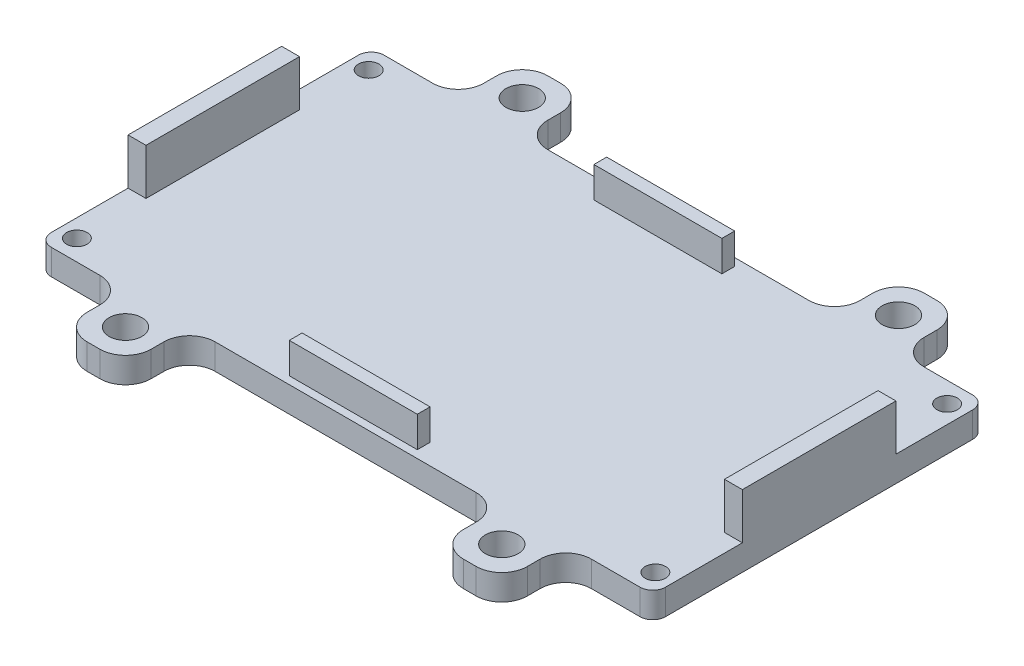
from build123d import *

# Parameters (mm, degrees)
SKETCH_1_W          = 120
SKETCH_1_H          = 65
EXTRUDE_1_DEPTH     = 5
SKETCH_2_W          = 12.5
SKETCH_2_H          = 12.5
EXTRUDE_2_DEPTH     = 5
SKETCH_3_R          = 3.2
CUT_EXTRUDE_1_DEPTH = 5
SKETCH_4_W          = 3.5
SKETCH_4_H          = 30
EXTRUDE_3_DEPTH     = 9
FILLET_1_R          = 5
FILLET_2_R          = 2.5
SKETCH_5_W          = 25
SKETCH_5_H          = 2.5
EXTRUDE_4_DEPTH     = 6
SKETCH_6_R          = 2
CUT_EXTRUDE_2_DEPTH = 10


with BuildPart() as part:
    # 草图1 → 凸台-拉伸1 (new body)
    with BuildSketch(Plane(origin=(0, 0, 0), x_dir=(1, 0, 0), z_dir=(0, 1, 0))):
        Rectangle(SKETCH_1_W, SKETCH_1_H)
    extrude(amount=EXTRUDE_1_DEPTH)

    # 草图2 → 凸台-拉伸2 (add)
    with BuildSketch(Plane(origin=(0, 5, 0), x_dir=(1, 0, 0), z_dir=(0, 1, 0))):
        with Locations((-36.75, 38.75)):
            Rectangle(SKETCH_2_W, SKETCH_2_H)
        with Locations((36.75, 38.75)):
            Rectangle(SKETCH_2_W, SKETCH_2_H)
        with Locations((36.75, -38.75)):
            Rectangle(SKETCH_2_W, SKETCH_2_H)
        with Locations((-36.75, -38.75)):
            Rectangle(SKETCH_2_W, SKETCH_2_H)
    extrude(amount=-EXTRUDE_2_DEPTH)

    # 草图3 → 切除-拉伸1 (cut)
    with BuildSketch(Plane(origin=(0, 5, 0), x_dir=(1, 0, 0), z_dir=(0, 1, 0))):
        with Locations((-36.75, 38.75)):
            Circle(SKETCH_3_R)
        with Locations((36.75, 38.75)):
            Circle(SKETCH_3_R)
        with Locations((36.75, -38.75)):
            Circle(SKETCH_3_R)
        with Locations((-36.75, -38.75)):
            Circle(SKETCH_3_R)
    extrude(amount=-CUT_EXTRUDE_1_DEPTH, mode=Mode.SUBTRACT)

    # 草图4 → 凸台-拉伸3 (add)
    with BuildSketch(Plane(origin=(0, 5, 0), x_dir=(1, 0, 0), z_dir=(0, 1, 0))):
        with Locations((-58.25, 0)):
            Rectangle(SKETCH_4_W, SKETCH_4_H)
        with Locations((58.25, 0)):
            Rectangle(SKETCH_4_W, SKETCH_4_H)
    extrude(amount=EXTRUDE_3_DEPTH)

    # 圆角1
    fillet_1_edges = [part.edges().sort_by_distance(p)[0] for p in [
        (-43, 2.5, -32.5),
        (-43, 2.5, -45),
        (-30.5, 2.5, -45),
        (-30.5, 2.5, -32.5),
        (43, 2.5, -32.5),
        (30.5, 2.5, -32.5),
        (30.5, 2.5, -45),
        (43, 2.5, -45),
        (30.5, 2.5, 32.5),
        (43, 2.5, 32.5),
        (43, 2.5, 45),
        (30.5, 2.5, 45),
        (-43, 2.5, 32.5),
        (-30.5, 2.5, 32.5),
        (-30.5, 2.5, 45),
        (-43, 2.5, 45),
    ]]
    fillet(fillet_1_edges, radius=FILLET_1_R)

    # 圆角2
    fillet_2_edges = [part.edges().sort_by_distance(p)[0] for p in [
        (60, 2.5, 32.5),
        (-60, 2.5, 32.5),
        (-60, 2.5, -32.5),
        (60, 2.5, -32.5),
    ]]
    fillet(fillet_2_edges, radius=FILLET_2_R)

    # 草图5 → 凸台-拉伸4 (add)
    with BuildSketch(Plane(origin=(0, 5, 0), x_dir=(1, 0, 0), z_dir=(0, 1, 0))):
        with Locations((0, 29.75)):
            Rectangle(SKETCH_5_W, SKETCH_5_H)
        with Locations((0, -29.75)):
            Rectangle(SKETCH_5_W, SKETCH_5_H)
    extrude(amount=EXTRUDE_4_DEPTH)

    # 草图6 → 切除-拉伸2 (cut)
    with BuildSketch(Plane(origin=(0, 5, 0), x_dir=(1, 0, 0), z_dir=(0, 1, 0))):
        with Locations((-56.5, 28.5)):
            Circle(SKETCH_6_R)
        with Locations((56.5, 28.5)):
            Circle(SKETCH_6_R)
        with Locations((56.5, -28.5)):
            Circle(SKETCH_6_R)
        with Locations((-56.5, -28.5)):
            Circle(SKETCH_6_R)
    extrude(amount=-CUT_EXTRUDE_2_DEPTH, mode=Mode.SUBTRACT)


solid = part.part
